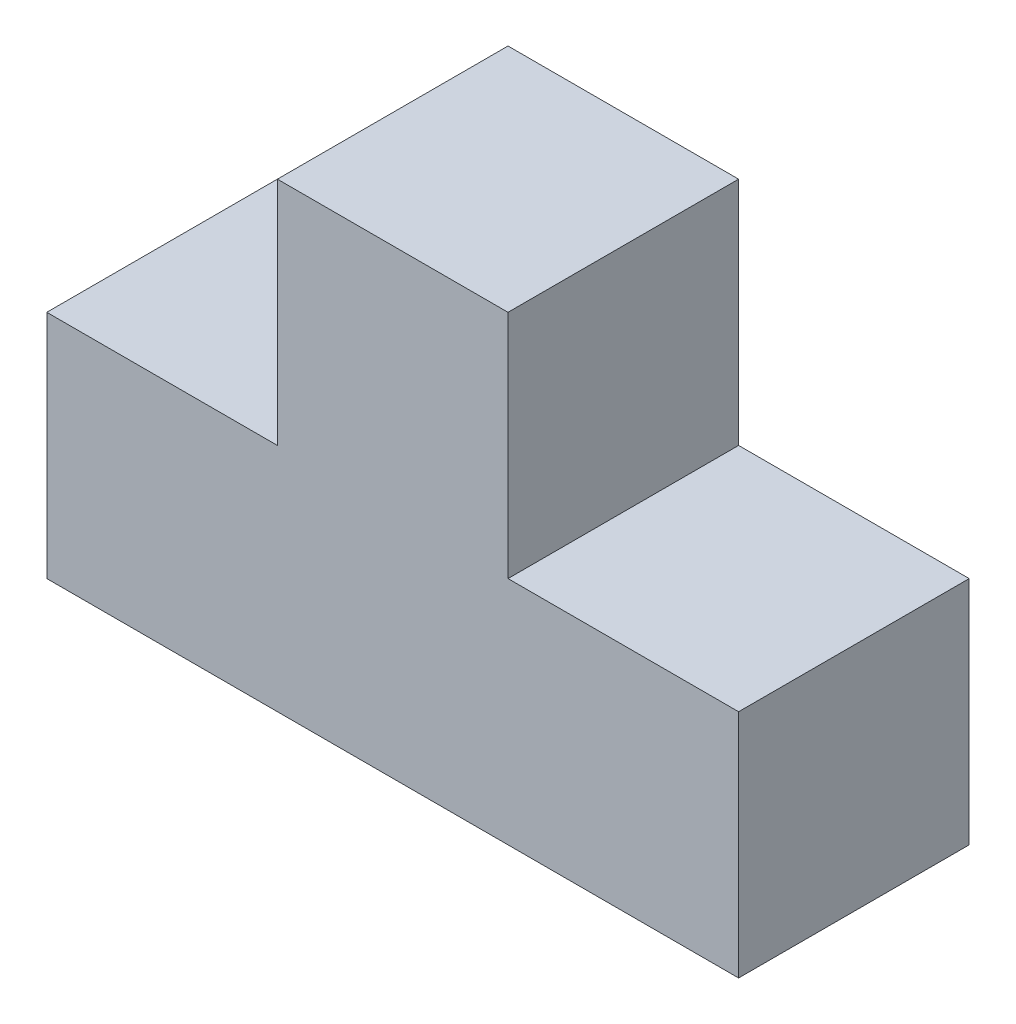
from build123d import *

# Parameters (mm, degrees)
BOSS_EXTRUDE1_DEPTH = 10


with BuildPart() as part:
    # Sketch1 → Boss-Extrude1 (new body)
    with BuildSketch(Plane.XY):
        Polygon((-50.725694783, 17.833252072), (-50.725694783, 7.833252072), (-46.27381765, 7.833252072), (-20.725694783, 7.833252072), (-20.725694783, 17.833252072), (-30.725694783, 17.833252072), (-30.725694783, 27.833252072), (-40.725694783, 27.833252072), (-40.725694783, 17.833252072), align=None)
    extrude(amount=BOSS_EXTRUDE1_DEPTH)


solid = part.part
